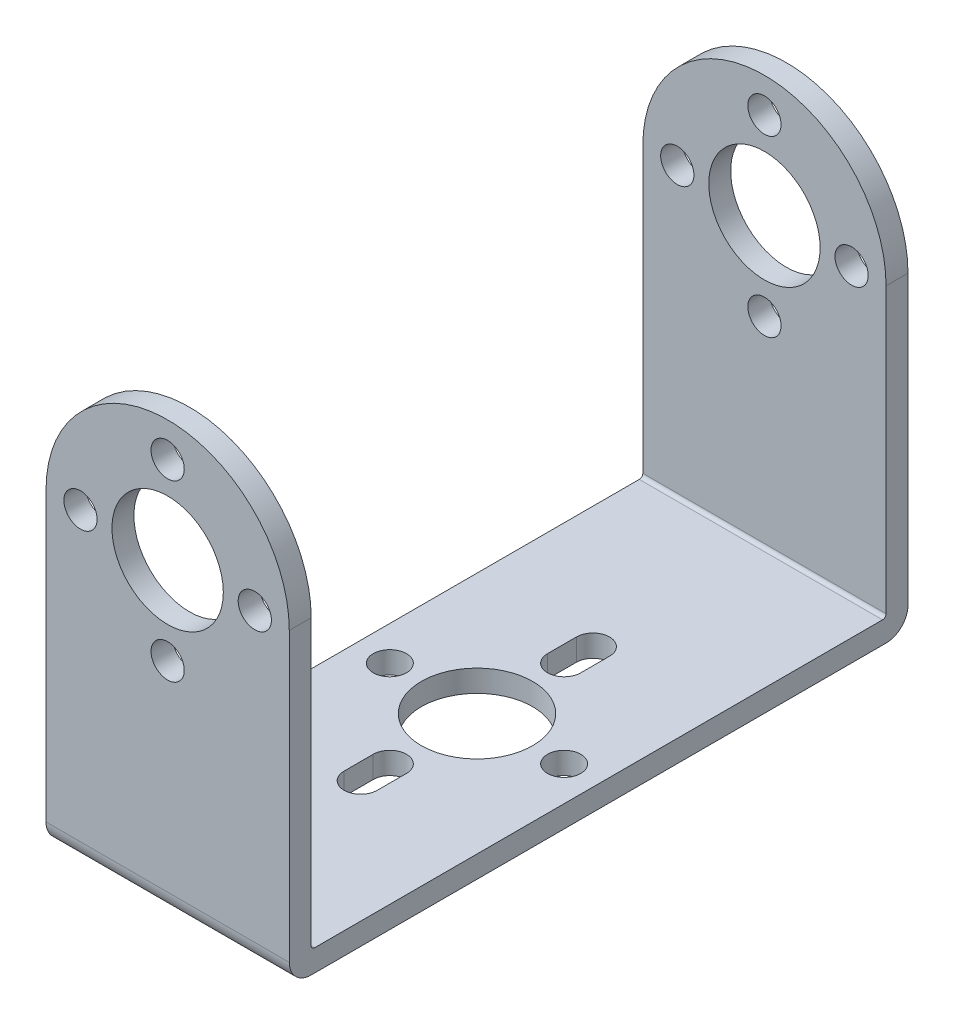
from build123d import *

# Parameters (mm, degrees)
SKETCH1_W         = 44.45
SKETCH1_H         = 30.9626
EXTRUDE1_DEPTH    = 17.4752
SKETCH2_W         = 41.3004
SKETCH2_H         = 29.3878
EXTRUDE2_DEPTH    = 17.4752
SKETCH3_OUTSIDE_W = 30.859
SKETCH3_OUTSIDE_H = 44.347
EXTRUDE3_DEPTH    = 45.45
SKETCH4_R         = 4.0005
SKETCH4_R_2       = 1.1938
EXTRUDE4_DEPTH    = 45.45
SKETCH5_R         = 4.0005
SKETCH5_R_2       = 1.1938
EXTRUDE5_DEPTH    = 17.4752
FILLET1_R         = 1.5748
FILLET2_R         = 0.254


with BuildPart() as part:
    # Sketch1 → Extrude1 (new body)
    with BuildSketch(Plane(origin=(0, 0, 0), x_dir=(0, 0, -1), z_dir=(1, 0, 0))):
        with Locations((22.225, 15.4813)):
            Rectangle(SKETCH1_W, SKETCH1_H)
    extrude(amount=EXTRUDE1_DEPTH)

    # Sketch2 → Extrude2 (cut)
    with BuildSketch(Plane(origin=(17.4752, 0, 0), x_dir=(0, 0, -1), z_dir=(1, 0, 0))):
        with Locations((22.225, 16.2687)):
            Rectangle(SKETCH2_W, SKETCH2_H)
    extrude(amount=-EXTRUDE2_DEPTH, mode=Mode.SUBTRACT)

    # Sketch3 outside → Extrude3 (cut, through all)
    with BuildSketch(Plane.XY):
        with Locations((8.7375, 15.4815)):
            Rectangle(SKETCH3_OUTSIDE_W, SKETCH3_OUTSIDE_H)
        with BuildLine():
            Line((0, 22.225), (0, 0))
            Line((0, 0), (17.4752, 0))
            Line((17.4752, 0), (17.4752, 22.225))
            ThreePointArc((17.4752, 22.225), (8.7376, 30.9626), (0, 22.225))
        make_face(mode=Mode.SUBTRACT)
    extrude(amount=-EXTRUDE3_DEPTH, mode=Mode.SUBTRACT)

    # Sketch4 → Extrude4 (cut, through all)
    with BuildSketch(Plane.XY):
        with Locations((8.7376, 22.225)):
            Circle(SKETCH4_R)
        with Locations((2.4765, 22.225)):
            Circle(SKETCH4_R_2)
        with Locations((14.9987, 22.225)):
            Circle(SKETCH4_R_2)
        with Locations((8.7376, 15.9639)):
            Circle(SKETCH4_R_2)
        with Locations((8.7376, 28.4861)):
            Circle(SKETCH4_R_2)
    extrude(amount=-EXTRUDE4_DEPTH, mode=Mode.SUBTRACT)

    # Sketch5 → Extrude5 (cut)
    with BuildSketch(Plane(origin=(0, 1.5748, 0), x_dir=(1, 0, 0), z_dir=(0, 1, 0))):
        with Locations(Location((8.7376, 22.225, 0), (0, 0, 270))):  # turned: the seam where the file's is
            Circle(SKETCH5_R)
        with Locations(Location((2.4765, 22.225, 0), (0, 0, 270))):  # turned: the seam where the file's is
            Circle(SKETCH5_R_2)
        with Locations(Location((14.9987, 22.225, 0), (0, 0, 270))):  # turned: the seam where the file's is
            Circle(SKETCH5_R_2)
        with BuildLine():
            Line((9.9314, 30.5562), (9.9314, 28.4861))
            ThreePointArc((9.9314, 28.4861), (8.7376, 27.2923), (7.5438, 28.4861))
            Line((7.5438, 28.4861), (7.5438, 30.5562))
            ThreePointArc((7.5438, 30.5562), (8.7376, 31.75), (9.9314, 30.5562))
        make_face()
        with BuildLine():
            Line((7.5438, 15.9639), (7.5438, 13.8684))
            ThreePointArc((7.5438, 13.8684), (8.7376, 12.6746), (9.9314, 13.8684))
            Line((9.9314, 13.8684), (9.9314, 15.9639))
            ThreePointArc((9.9314, 15.9639), (8.7376, 17.1577), (7.5438, 15.9639))
        make_face()
    extrude(amount=-EXTRUDE5_DEPTH, mode=Mode.SUBTRACT)

    # Fillet1
    fillet1_edges = [part.edges().sort_by_distance(p)[0] for p in [
        (8.7376, 0, -44.45),
        (8.7376, 0, 0),
    ]]
    fillet(fillet1_edges, radius=FILLET1_R)

    # Fillet2
    fillet2_edges = [part.edges().sort_by_distance(p)[0] for p in [
        (8.7376, 1.5748, -42.8752),
        (8.7376, 1.5748, -1.5748),
    ]]
    fillet(fillet2_edges, radius=FILLET2_R)


solid = part.part
